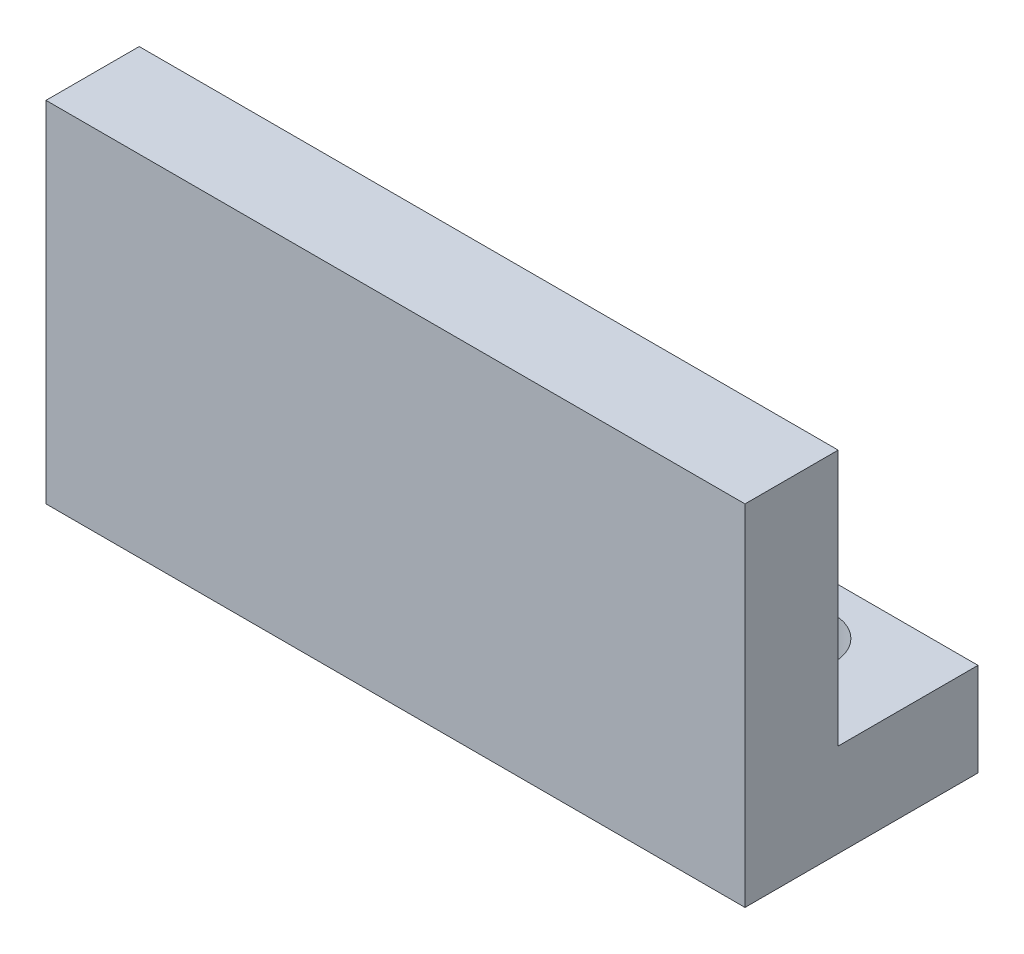
from build123d import *

# Parameters (mm, degrees)
BOSS_EXTRUDE1_DEPTH  = 30
M3_CLEARANCE_HOLE1_D = 3.6


with BuildPart() as part:
    # Sketch1 → Boss-Extrude1 (new body)
    with BuildSketch(Plane(origin=(0, 0, 0), x_dir=(0, 0, -1), z_dir=(1, 0, 0))):
        Polygon((0, 15), (0, 0), (10, 0), (10, 4), (4, 4), (4, 15), align=None)
    extrude(amount=BOSS_EXTRUDE1_DEPTH)

    # M3 Clearance Hole1 (through all)
    with Locations(Plane(origin=(0, 4, 0), x_dir=(1, 0, 0), z_dir=(0, 1, 0))):
        with Locations((5, 7), (25, 7)):
            Hole(M3_CLEARANCE_HOLE1_D / 2)


solid = part.part
